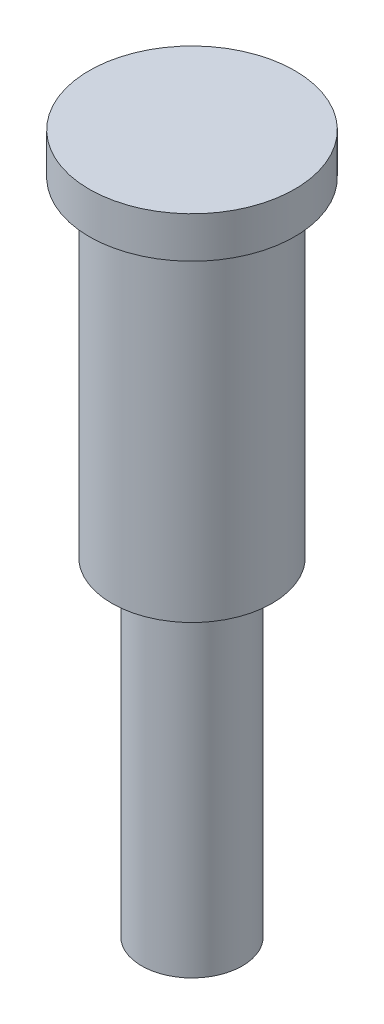
from build123d import *

# Parameters (mm, degrees)
SKETCH1_R           = 5
BOSS_EXTRUDE1_DEPTH = 2
SKETCH4_R           = 3.9
BOSS_EXTRUDE2_DEPTH = 16
SKETCH6_R           = 2.45
SKETCH6_R_2         = 1.6
BOSS_EXTRUDE3_DEPTH = 16


with BuildPart() as part:
    # Sketch1 → Boss-Extrude1 (new body)
    with BuildSketch(Plane(origin=(0, 0, 0), x_dir=(1, 0, 0), z_dir=(0, 1, 0))):
        Circle(SKETCH1_R)
    extrude(amount=BOSS_EXTRUDE1_DEPTH)

    # Sketch4 → Boss-Extrude2 (add)
    with BuildSketch(Plane(origin=(0, 0, 0), x_dir=(-1, 0, 0), z_dir=(0, -1, 0))):
        Circle(SKETCH4_R)
    extrude(amount=BOSS_EXTRUDE2_DEPTH)

    # Sketch6 → Boss-Extrude3 (add)
    with BuildSketch(Plane(origin=(0, -16, 0), x_dir=(-1, 0, 0), z_dir=(0, -1, 0))):
        Circle(SKETCH6_R)
        Circle(SKETCH6_R_2, mode=Mode.SUBTRACT)
    extrude(amount=BOSS_EXTRUDE3_DEPTH)


solid = part.part
